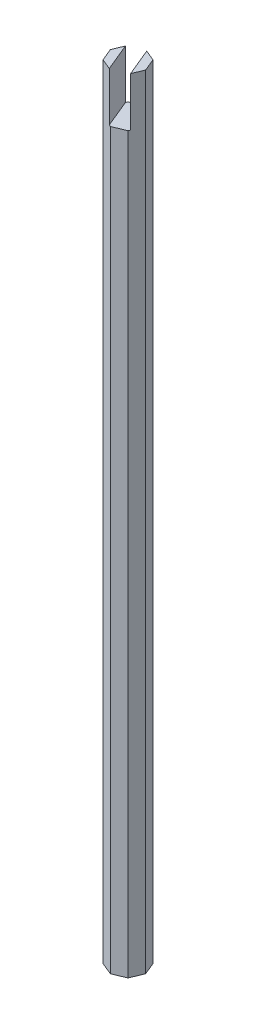
from build123d import *

# Parameters (mm, degrees)
BOSS_EXTRUDE1_DEPTH = 609.6
CUT_EXTRUDE1_DEPTH  = 38.1


with BuildPart() as part:
    # Sketch1 → Boss-Extrude1 (new body)
    with BuildSketch(Plane(origin=(0, 0, 0), x_dir=(1, 0, 0), z_dir=(0, 1, 0))):
        Polygon((13.746380944, 0), (9.720159182, 9.720159182), (0, 13.746380944), (-9.720159182, 9.720159182), (-13.746380944, 0), (-9.720159182, -9.720159182), (0, -13.746380944), (9.720159182, -9.720159182), align=None)
    extrude(amount=BOSS_EXTRUDE1_DEPTH)

    # Sketch2 → Cut-Extrude1 (cut)
    with BuildSketch(Plane(origin=(0, 609.6, 0), x_dir=(1, 0, 0), z_dir=(0, 1, 0))):
        Polygon((-1.00655544, -14.163309858), (-10.726714622, 9.303230267), (1.00655544, 14.163309858), (10.726714622, -9.303230267), align=None)
    extrude(amount=-CUT_EXTRUDE1_DEPTH, mode=Mode.SUBTRACT)


solid = part.part
